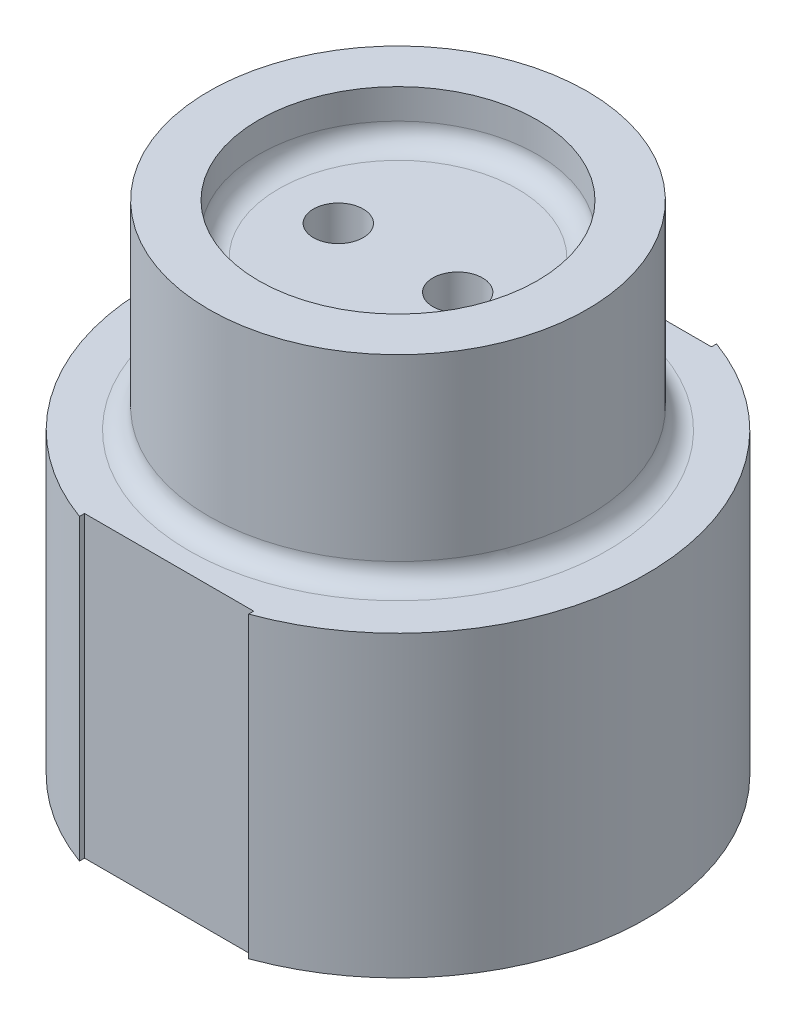
from build123d import *

# Parameters (mm, degrees)
SKETCH4_R           = 35.56
BOSS_EXTRUDE1_DEPTH = 7.62
SKETCH5_R           = 8.89
SKETCH5_R_2         = 6.35
SKETCH7_R           = 6.35
CUT_EXTRUDE1_DEPTH  = 13.7
SKETCH8_R           = 6.35
CUT_EXTRUDE2_DEPTH  = 7.62
SKETCH10_W          = 43.18
SKETCH10_H          = 76.2
CUT_EXTRUDE3_DEPTH  = 5.08
FILLET1_R           = 5.08
FILLET2_R           = 5.08


with BuildPart() as part:
    # Sketch3 → Revolve1 (revolve)
    with BuildSketch(Plane.XY):
        Polygon((0, 0), (63.5, 0), (63.5, 76.2), (48.26, 76.2), (48.26, 127), (35.56, 127), (35.56, 63.5), (50.8, 63.5), (50.8, 12.7), (0, 12.7), align=None)
    revolve(axis=Axis((0, 12.7, 0), (0, -1, 0)))

    # Sketch4 → Boss-Extrude1 (add)
    with BuildSketch(Plane(origin=(0, 114.3, 0), x_dir=(1, 0, 0), z_dir=(0, 1, 0))):
        Circle(SKETCH4_R)
    extrude(amount=-BOSS_EXTRUDE1_DEPTH)

    # Sweep1: sweep along a path in Sketch6
    with BuildLine(Plane.XY) as sweep1_path:
        Line((15.24, 114.3), (15.24, 50.8))
        Line((15.24, 50.8), (33.02, 50.8))
        Line((33.02, 50.8), (33.02, 12.7))
    # Sketch5 → Sweep1 (sweep)
    with BuildSketch(Plane(origin=(0, 114.3, 0), x_dir=(1, 0, 0), z_dir=(0, 1, 0))):
        with Locations((15.24, 0)):
            Circle(SKETCH5_R)
        with Locations((15.24, 0)):
            Circle(SKETCH5_R_2, mode=Mode.SUBTRACT)
    sweep1 = sweep(path=sweep1_path.line, transition=Transition.RIGHT)

    # Sketch7 → Cut-Extrude1 (cut, through all)
    with BuildSketch(Plane(origin=(0, 12.7, 0), x_dir=(1, 0, 0), z_dir=(0, 1, 0))):
        with Locations((33.02, 0)):
            Circle(SKETCH7_R)
    cut_extrude1 = extrude(amount=-CUT_EXTRUDE1_DEPTH, mode=Mode.SUBTRACT)

    # Sketch8 → Cut-Extrude2 (cut)
    with BuildSketch(Plane.XZ.offset(-106.68)):
        with Locations((15.24, 0)):
            Circle(SKETCH8_R)
    cut_extrude2 = extrude(amount=-CUT_EXTRUDE2_DEPTH, mode=Mode.SUBTRACT)

    # Mirror1: Sweep1, Cut-Extrude1, Cut-Extrude2 across plane
    add(sweep1.mirror(Plane(origin=(0, 0, 0), x_dir=(0, 0, 1), z_dir=(1, 0, 0))))
    add(cut_extrude1.mirror(Plane(origin=(0, 0, 0), x_dir=(0, 0, 1), z_dir=(1, 0, 0))), mode=Mode.SUBTRACT)
    add(cut_extrude2.mirror(Plane(origin=(0, 0, 0), x_dir=(0, 0, 1), z_dir=(1, 0, 0))), mode=Mode.SUBTRACT)

    # Sketch10 → Cut-Extrude3 (cut)
    with BuildSketch(Plane.XY.offset(63.5)):
        with Locations((0, 38.1)):
            Rectangle(SKETCH10_W, SKETCH10_H)
    cut_extrude3 = extrude(amount=-CUT_EXTRUDE3_DEPTH, mode=Mode.SUBTRACT)

    # Mirror2: Cut-Extrude3 across plane
    add(cut_extrude3.mirror(Plane.XY), mode=Mode.SUBTRACT)

    # Fillet1
    fillet1_edges = [part.edges().sort_by_distance(p)[0] for p in [
        (-35.56, 114.3, 0),
    ]]
    fillet(fillet1_edges, radius=FILLET1_R)

    # Fillet2
    fillet2_edges = [part.edges().sort_by_distance(p)[0] for p in [
        (-48.26, 76.2, 0),
    ]]
    fillet(fillet2_edges, radius=FILLET2_R)


solid = part.part
